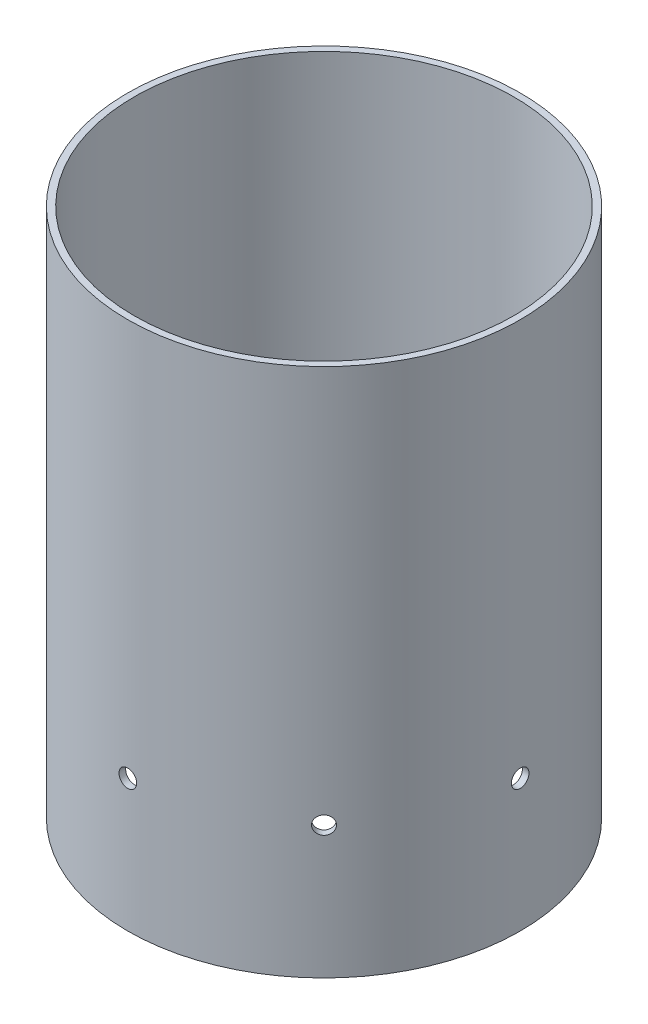
from build123d import *

# Parameters (mm, degrees)
SKIZZE1_R                       = 44.5
SKIZZE1_R_2                     = 43
AUFSATZ_LINEAR_AUSTRAGEN1_DEPTH = 120
SKIZZE2_R                       = 4
SCHNITT_LINEAR_AUSTRAGEN1_DEPTH = 45.5
SKIZZE3_R                       = 2
SCHNITT_LINEAR_AUSTRAGEN2_DEPTH = 45.5000001
KREISMUSTER1_COUNT              = 8
SKIZZE4_W                       = 24
SKIZZE4_H                       = 24.318999769
SCHNITT_LINEAR_AUSTRAGEN3_DEPTH = 45.50000012
VERRUNDUNG1_R                   = 2


with BuildPart() as part:
    # Skizze1 → Aufsatz-Linear austragen1 (new body)
    with BuildSketch(Plane(origin=(0, 0, 0), x_dir=(1, 0, 0), z_dir=(0, 1, 0))):
        Circle(SKIZZE1_R)
        Circle(SKIZZE1_R_2, mode=Mode.SUBTRACT)
    extrude(amount=AUFSATZ_LINEAR_AUSTRAGEN1_DEPTH)

    # Skizze2 → Schnitt-Linear austragen1 (cut, through all)
    with BuildSketch(Plane.XY):
        with Locations((0, 50)):
            Circle(SKIZZE2_R)
    extrude(amount=-SCHNITT_LINEAR_AUSTRAGEN1_DEPTH, mode=Mode.SUBTRACT)

    # Skizze3 → Schnitt-Linear austragen2 (cut, through all)
    with BuildSketch(Plane.XY):
        with Locations((0, 30)):
            Circle(SKIZZE3_R)
    schnitt_linear_austragen2 = extrude(amount=-SCHNITT_LINEAR_AUSTRAGEN2_DEPTH, mode=Mode.SUBTRACT)

    # Kreismuster1: Schnitt-Linear austragen2 ×8 about axis
    kreismuster1_axis = Axis((0, 120, 0), (0, -1, 0))
    for i in range(1, KREISMUSTER1_COUNT):
        add(schnitt_linear_austragen2.rotate(kreismuster1_axis, i * 360 / KREISMUSTER1_COUNT), mode=Mode.SUBTRACT)

    # Skizze4 → Schnitt-Linear austragen3 (cut, through all)
    with BuildSketch(Plane.XY):
        with Locations((2, 12.159499885)):
            Rectangle(SKIZZE4_W, SKIZZE4_H)
    extrude(amount=-SCHNITT_LINEAR_AUSTRAGEN3_DEPTH, mode=Mode.SUBTRACT)

    # Verrundung1
    verrundung1_edges = [part.edges().sort_by_distance(p)[0] for p in [
        (-10, 24.318999769, -42.591448462),
        (14, 24.318999769, -41.448743111),
    ]]
    fillet(verrundung1_edges, radius=VERRUNDUNG1_R)


solid = part.part
